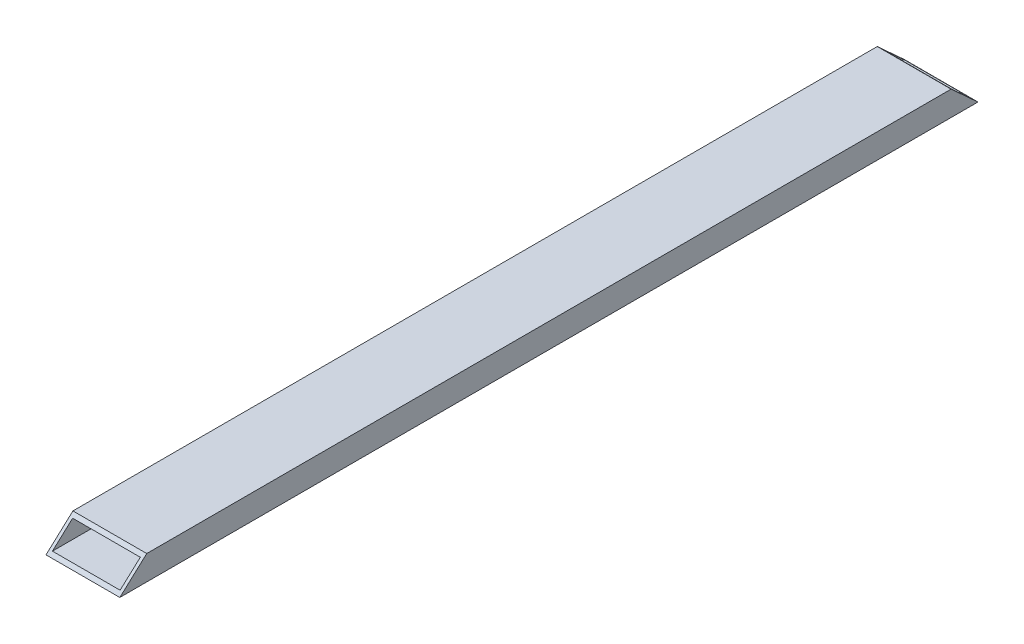
from build123d import *

# Parameters (mm, degrees)
SKETCH3_W           = 76.2
SKETCH3_H           = 25.4
SKETCH3_W_2         = 69.85
SKETCH3_H_2         = 19.05
BOSS_EXTRUDE1_DEPTH = 457.2
SKETCH4_W           = 14.2875
SKETCH4_H           = 25.4
CUT_EXTRUDE1_DEPTH  = 464.680461094


with BuildPart() as part:
    # Sketch3 → Boss-Extrude1 (new, symmetric)
    with BuildSketch(Plane.XY):
        Rectangle(SKETCH3_W, SKETCH3_H)
        Rectangle(SKETCH3_W_2, SKETCH3_H_2, mode=Mode.SUBTRACT)
    extrude(amount=BOSS_EXTRUDE1_DEPTH, both=True)

    # Sketch4 → Cut-Extrude1 (cut, through all)
    with BuildSketch(Plane(origin=(38.1, 0, 0), x_dir=(0, 0, -1), z_dir=(1, 0, 0))):
        with Locations((-450.05625, 0)):
            Rectangle(SKETCH4_W, SKETCH4_H)
        Polygon((-442.9125, -12.7), (-415.13125, 12.7), (-442.9125, 12.7), align=None)
        with Locations((450.05625, 0)):
            Rectangle(SKETCH4_W, SKETCH4_H)
        Polygon((442.9125, -12.7), (442.9125, 12.7), (415.13125, 12.7), align=None)
    extrude(amount=-CUT_EXTRUDE1_DEPTH, mode=Mode.SUBTRACT)


solid = part.part
